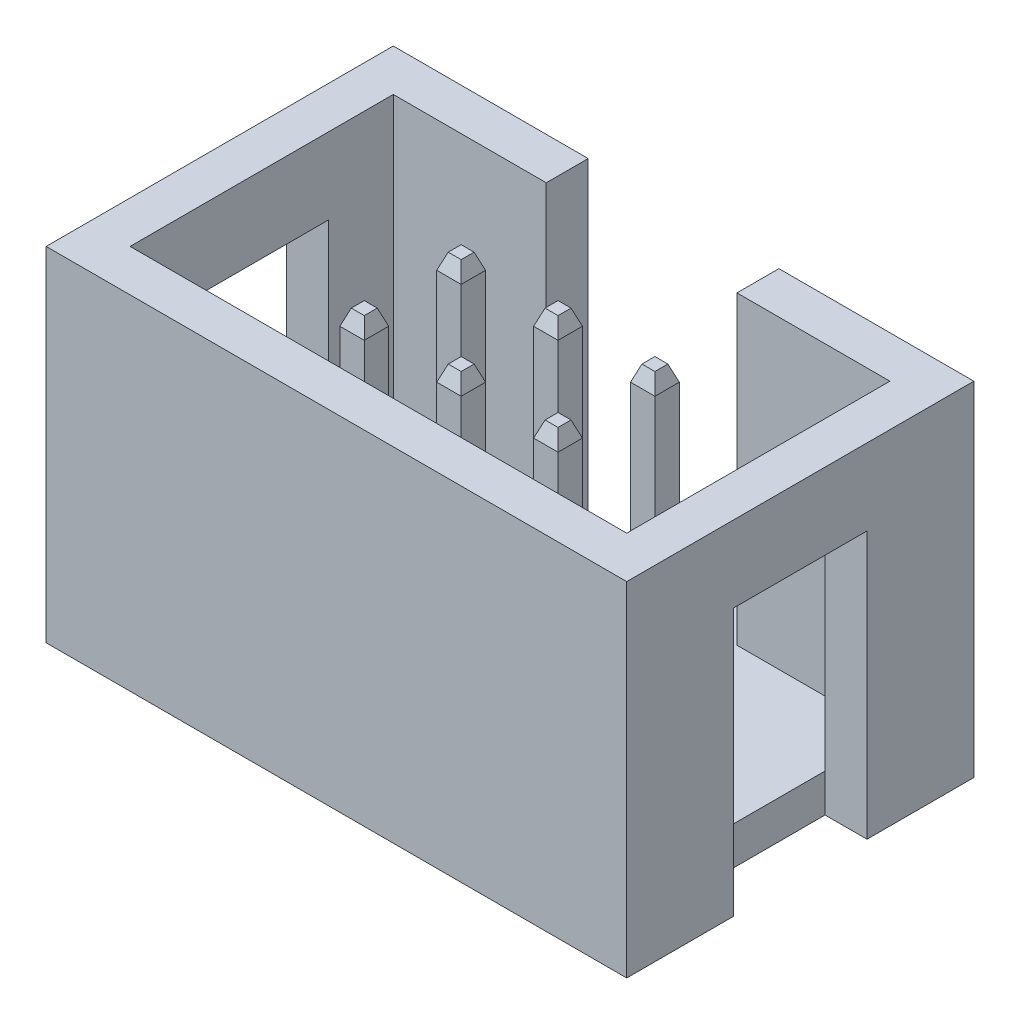
from build123d import *

# Parameters (mm, degrees)
SKETCH_1_W               = 0.64
SKETCH_1_H               = 0.64
EXTRUDE_1_DEPTH          = 8.5
EXTRUDE_1_DEPTH_BACK     = 3
CHAMFER_1_SIZE           = 0.15
CHAMFER_1_SIZE2          = 0.412121613
CHAMFER_1_PART_2_SIZE    = 0.15
CHAMFER_1_PART_2_SIZE2   = 0.412121613
PATTERN_LINEAR_1_COUNT   = 3
PATTERN_LINEAR_1_PITCH   = 2.54
PATTERN_LINEAR_1_2_COUNT = 2
PATTERN_LINEAR_1_2_PITCH = 2.54
SKETCH_2_W               = 13.02
SKETCH_2_H               = 6.9
SKETCH_2_W_2             = 0.64
SKETCH_2_H_2             = 0.64
SKETCH_2_W_3             = 5
SKETCH_2_H_3             = 1.1
EXTRUDE_2_DEPTH          = 1
EXTRUDE_3_DEPTH          = 9
SKETCH_3_W               = 1.1
SKETCH_3_H               = 3.5
CUT_EXTRUDE_2_DEPTH      = 7


with BuildPart() as part:
    # Эскиз1 → Бобышка-Вытянуть1 (new body, two sides)
    with BuildSketch(Plane(origin=(0, 0, 0), x_dir=(1, 0, 0), z_dir=(0, 1, 0))) as extrude_1_sk:
        Rectangle(SKETCH_1_W, SKETCH_1_H)
    extrude(amount=EXTRUDE_1_DEPTH)
    extrude(extrude_1_sk.sketch, amount=-EXTRUDE_1_DEPTH_BACK)

    # Фаска1
    chamfer_1_edges = [part.edges().sort_by_distance(p)[0] for p in [
        (0.32, -3, 0),
        (0, -3, 0.32),
        (-0.32, -3, 0),
        (0, -3, -0.32),
    ]]
    chamfer_1_side = [part.faces().sort_by_distance(p)[0] for p in [
        (0, -3, 0),
    ]]
    chamfer(chamfer_1_edges, length=CHAMFER_1_SIZE, length2=CHAMFER_1_SIZE2, reference=chamfer_1_side[0])

    # Фаска1 part 2
    chamfer_1_part_2_edges = [part.edges().sort_by_distance(p)[0] for p in [
        (-0.32, 8.5, 0),
        (0, 8.5, -0.32),
        (0, 8.5, 0.32),
        (0.32, 8.5, 0),
    ]]
    chamfer_1_part_2_side = [part.faces().sort_by_distance(p)[0] for p in [
        (0, 8.5, 0),
    ]]
    chamfer(chamfer_1_part_2_edges, length=CHAMFER_1_PART_2_SIZE, length2=CHAMFER_1_PART_2_SIZE2, reference=chamfer_1_part_2_side[0])


with BuildPart() as pattern_linear_1_1:
    # Линейный массив1: pattern copy
    add(part.part.moved(Location(Vector(1, 0, 0) * (1 * PATTERN_LINEAR_1_PITCH))))


with BuildPart() as pattern_linear_1_2:
    # Линейный массив1: pattern copy
    add(part.part.moved(Location(Vector(1, 0, 0) * (2 * PATTERN_LINEAR_1_PITCH))))


with BuildPart() as pattern_linear_1_2_1:
    # Pattern Linear 1 2: pattern copy
    add(part.part.moved(Location(Vector(0, 0, 1) * (1 * PATTERN_LINEAR_1_2_PITCH))))


with BuildPart() as pattern_linear_1_2_2:
    # Pattern Linear 1 2: pattern copy
    add(pattern_linear_1_1.part.moved(Location(Vector(0, 0, 1) * (1 * PATTERN_LINEAR_1_2_PITCH))))


with BuildPart() as pattern_linear_1_2_3:
    # Pattern Linear 1 2: pattern copy
    add(pattern_linear_1_2.part.moved(Location(Vector(0, 0, 1) * (1 * PATTERN_LINEAR_1_2_PITCH))))


with BuildPart() as part_1:
    add(part.part)

    add(pattern_linear_1_1.part)  # Бобышка-Вытянуть2 merges Линейный массив1_1

    add(pattern_linear_1_2.part)  # Бобышка-Вытянуть2 merges Линейный массив1_2

    add(pattern_linear_1_2_1.part)  # Бобышка-Вытянуть2 merges Линейный массив1 2_1

    add(pattern_linear_1_2_2.part)  # Бобышка-Вытянуть2 merges Линейный массив1 2_2

    add(pattern_linear_1_2_3.part)  # Бобышка-Вытянуть2 merges Линейный массив1 2_3
    # Эскиз2 → Бобышка-Вытянуть2 (add)
    with BuildSketch(Plane(origin=(0, 0, 0), x_dir=(1, 0, 0), z_dir=(0, 1, 0))):
        with Locations((2.54, -1.259333449)):
            Rectangle(SKETCH_2_W, SKETCH_2_H)
        with Locations((0, -2.54)):
            Rectangle(SKETCH_2_W_2, SKETCH_2_H_2, mode=Mode.SUBTRACT)
        with Locations((5.08, -2.54)):
            Rectangle(SKETCH_2_W_2, SKETCH_2_H_2, mode=Mode.SUBTRACT)
        with Locations((2.54, -2.54)):
            Rectangle(SKETCH_2_W_2, SKETCH_2_H_2, mode=Mode.SUBTRACT)
        with Locations((5.08, 0)):
            Rectangle(SKETCH_2_W_2, SKETCH_2_H_2, mode=Mode.SUBTRACT)
        with Locations((2.54, 0)):
            Rectangle(SKETCH_2_W_2, SKETCH_2_H_2, mode=Mode.SUBTRACT)
        Rectangle(SKETCH_2_W_2, SKETCH_2_H_2, mode=Mode.SUBTRACT)
        with Locations((2.54, 2.740666551)):
            Rectangle(SKETCH_2_W_3, SKETCH_2_H_3)
    extrude(amount=EXTRUDE_2_DEPTH)

    # Эскиз2<3> → Бобышка-Вытянуть3 (add)
    with BuildSketch(Plane(origin=(0, 0, 0), x_dir=(1, 0, 0), z_dir=(0, 1, 0))):
        Polygon((-5.07, 3.290666551), (-5.07, -5.809333449), (10.15, -5.809333449), (10.15, 3.290666551), (5.04, 3.290666551), (5.04, 2.190666551), (9.05, 2.190666551), (9.05, -4.709333449), (-3.97, -4.709333449), (-3.97, 2.190666551), (0.04, 2.190666551), (0.04, 3.290666551), align=None)
    extrude(amount=EXTRUDE_3_DEPTH)

    # Эскиз3 → Вырез-Вытянуть2 (cut)
    with BuildSketch(Plane.XZ):
        with Locations((-4.52, 1.259333449)):
            Rectangle(SKETCH_3_W, SKETCH_3_H)
        with Locations((9.6, 1.259333449)):
            Rectangle(SKETCH_3_W, SKETCH_3_H)
    extrude(amount=-CUT_EXTRUDE_2_DEPTH, mode=Mode.SUBTRACT)


solid = part_1.part
